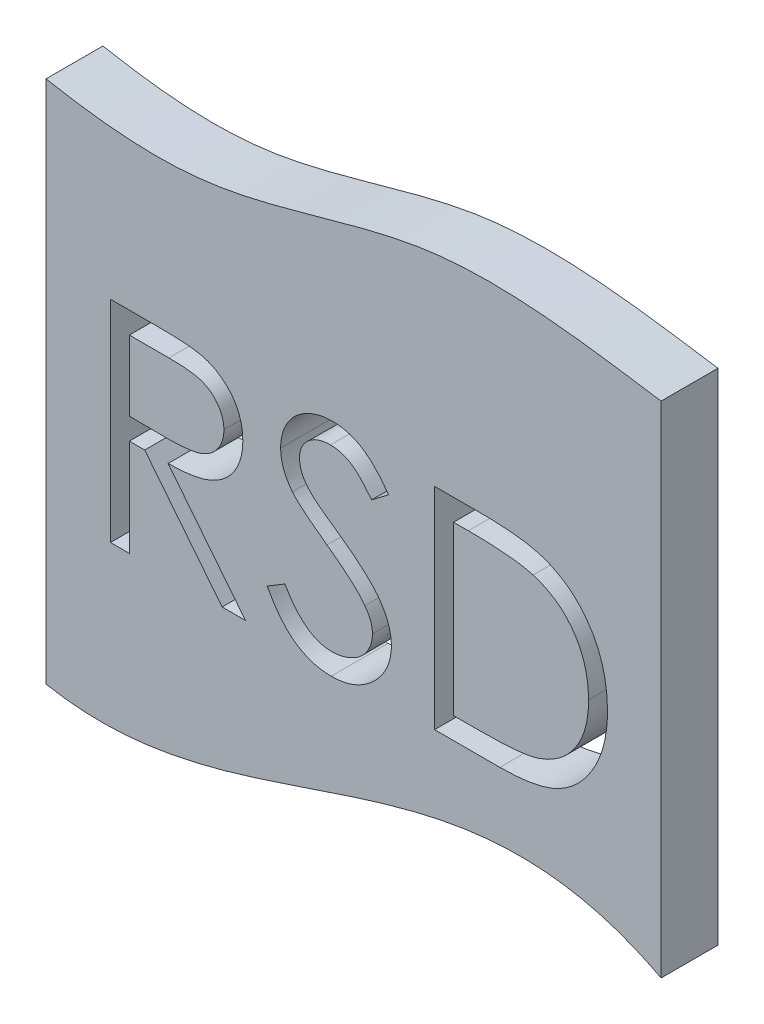
from build123d import *

# Parameters (mm, degrees)
BOSS_EXTRUDE2_DEPTH = 50
CUT_EXTRUDE3_DEPTH  = 50


with BuildPart() as part:
    # Sketch4 → Boss-Extrude2 (new body)
    with BuildSketch(Plane.XY):
        with BuildLine():
            Line((-253.859566444, 177.777181876), (-253.859566444, -283.005856695))
            add(Edge.make_bspline(
                [(-253.859566444, -283.005856695), (-207.170598057, -291.878132089), (-28.434679126, -271.164662134), (144.41760812, -161.038723154), (286.771817679, -236.372653984)],
                knots=[0.159405612, 0.159405612, 0.159405612, 0.159405612, 0.373982024, 1, 1, 1, 1], degree=3))
            Line((286.771817679, -236.372653984), (286.771817679, 202.798469011))
            add(Edge.make_bspline(
                [(-253.859566444, 177.777181876), (-207.700562223, 169.018800488), (-94.63538463, 157.865945475), (81.209450827, 234.424705463), (218.105040902, 213.363008386), (286.771817679, 202.798469011)],
                knots=[0.162783467, 0.162783467, 0.162783467, 0.162783467, 0.375755947, 0.686879417, 1, 1, 1, 1], degree=3))
        make_face()
    extrude(amount=BOSS_EXTRUDE2_DEPTH)

    # Sketch5 → Cut-Extrude3 (cut)
    with BuildSketch(Plane.XY.offset(50)):
        with BuildLine():
            Line((-197.245797461, 38.343525558), (-160.181870177, 38.343525558))
            add(Edge.make_bspline(
                [(-160.181870177, 38.343525558), (-155.4336297, 38.316492782), (-148.627104323, 38.331563473), (-139.973554774, 37.978720031), (-134.416174474, 37.76159426), (-129.484068309, 37.36377549), (-124.131071162, 36.899953135), (-120.448225941, 36.31907212), (-118.220607156, 35.820655633)],
                knots=[0, 0, 0, 0, 0.338434414, 0.484822051, 0.617157578, 0.734698361, 0.837385184, 1, 1, 1, 1], degree=3))
            add(Edge.make_bspline(
                [(-118.220607156, 35.820655633), (-115.522888444, 35.227944972), (-111.600210412, 33.991945188), (-106.64597839, 31.801900044), (-103.164274698, 29.900187843), (-99.897508952, 27.699825482), (-96.811475012, 25.240984948), (-93.892309247, 22.536535556), (-91.25802815, 19.518449015), (-88.774175902, 16.352098606), (-86.679257402, 12.928191369), (-84.873472947, 9.347771042), (-83.43541583, 5.574411492), (-82.278794332, 1.644759507), (-81.167985575, -3.935337325), (-80.889371197, -8.258757512), (-80.896972674, -11.186347238)],
                knots=[0, 0, 0, 0, 0.127063766, 0.188744538, 0.249132103, 0.309452533, 0.369826676, 0.430650142, 0.492351932, 0.554072106, 0.615689784, 0.676797703, 0.738439048, 0.80131691, 0.865184512, 1, 1, 1, 1], degree=3))
            add(Edge.make_bspline(
                [(-80.896972674, -11.186347238), (-80.880089433, -15.992319417), (-81.698527638, -23.126866777), (-84.859650144, -31.976518581), (-88.048528797, -38.01744681), (-92.114416305, -43.463182357), (-96.999706707, -48.246331358), (-102.708505903, -52.248946618), (-108.022874338, -55.024574308), (-112.717336352, -56.802196988), (-116.58201545, -58.052961732), (-120.797725883, -59.019293307), (-125.324078983, -59.885143673), (-130.179895437, -60.538235261), (-137.287689434, -61.198806908), (-142.791377097, -61.370129199), (-146.565792787, -61.384038545)],
                knots=[0, 0, 0, 0, 0.153720644, 0.22671353, 0.299191166, 0.371189997, 0.443006414, 0.516689173, 0.593217217, 0.633872918, 0.676989142, 0.722899506, 0.771958611, 0.824211323, 0.879378651, 1, 1, 1, 1], degree=3))
            Line((-146.565792787, -61.384038545), (-78.522506862, -146.864807775))
            Line((-78.522506862, -146.864807775), (-99.076476547, -146.864807775))
            Line((-99.076476547, -146.864807775), (-167.119762471, -61.384038545))
            Line((-167.119762471, -61.384038545), (-180.624536777, -61.384038545))
            Line((-180.624536777, -61.384038545), (-180.624536777, -146.864807775))
            Line((-180.624536777, -146.864807775), (-197.245797461, -146.864807775))
            Line((-197.245797461, -146.864807775), (-197.245797461, 38.343525558))
        make_face()
        with BuildLine():
            Line((-180.624536777, 19.347799062), (-180.624536777, -42.388312049))
            Line((-180.624536777, -42.388312049), (-146.7141969, -42.648019247))
            add(Edge.make_bspline(
                [(-146.7141969, -42.648019247), (-143.644599597, -42.697311401), (-139.2027504, -42.534467377), (-133.488513008, -42.197702403), (-129.676344177, -41.830733338), (-126.184187112, -41.356626827), (-123.013768157, -40.763844531), (-120.159917334, -40.073163056), (-116.831534127, -39.004163072), (-113.114865707, -37.310510084), (-109.075601714, -34.846419418), (-105.636101452, -31.747136976), (-102.729264597, -28.203124184), (-100.396920834, -24.306542188), (-98.178575391, -18.679287666), (-97.506840319, -14.174786166), (-97.518233358, -11.14924621)],
                knots=[0, 0, 0, 0, 0.138913286, 0.20118457, 0.259124428, 0.312255041, 0.36068151, 0.405086143, 0.445101659, 0.51877778, 0.589461579, 0.658462242, 0.727283218, 0.796322487, 0.863174893, 1, 1, 1, 1], degree=3))
            add(Edge.make_bspline(
                [(-97.518233358, -11.14924621), (-97.528006954, -8.205288588), (-98.140544416, -3.76200421), (-100.479411083, 1.690880257), (-102.822313414, 5.509423376), (-105.68044231, 8.975812206), (-109.030833127, 11.941629299), (-112.782947281, 14.388999768), (-116.289786294, 15.952918691), (-119.424265125, 16.911760148), (-122.145750927, 17.586512508), (-125.220816523, 18.12860101), (-128.664393856, 18.563007973), (-132.461775715, 18.936054969), (-138.249691605, 19.286660183), (-142.768402967, 19.358323321), (-145.897974277, 19.347799062)],
                knots=[0, 0, 0, 0, 0.136364825, 0.204019354, 0.273063739, 0.34291332, 0.410965444, 0.479168767, 0.549308007, 0.587651576, 0.630646669, 0.678878786, 0.731934299, 0.791111423, 0.85528319, 1, 1, 1, 1], degree=3))
            Line((-145.897974277, 19.347799062), (-180.624536777, 19.347799062))
        make_face(mode=Mode.SUBTRACT)
        with BuildLine():
            Line((-59.526780367, -111.136517511), (-43.870146419, -101.749957348))
            add(Edge.make_bspline(
                [(-43.870146419, -101.749957348), (-41.15894546, -106.456604833), (-36.8772392, -113.057045278), (-30.146479571, -120.53154576), (-25.121180156, -124.919030584), (-19.920952012, -128.367026978), (-12.777482046, -131.618288966), (-7.017325499, -132.6280394), (-3.207419389, -132.618012903)],
                knots=[0, 0, 0, 0, 0.3046461, 0.438546905, 0.562322299, 0.677432543, 0.786897393, 1, 1, 1, 1], degree=3))
            add(Edge.make_bspline(
                [(-3.207419389, -132.618012903), (0.013579203, -132.647062287), (4.812980182, -132.081140873), (10.977799759, -130.296090153), (15.349212047, -128.403029714), (19.428835368, -126.109059344), (23.006394867, -123.339232203), (26.099039367, -120.237962105), (28.629405444, -116.778081742), (30.568696785, -113.057343717), (32.561815547, -107.974358255), (33.028454039, -103.89911073), (33.0773863, -101.230542952)],
                knots=[0, 0, 0, 0, 0.180930311, 0.27008822, 0.360156133, 0.448342532, 0.532665842, 0.613833704, 0.693981527, 0.772715977, 0.849335172, 1, 1, 1, 1], degree=3))
            add(Edge.make_bspline(
                [(33.0773863, -101.230542952), (33.094815335, -98.09243764), (31.830914969, -91.545159102), (28.455217203, -85.811421857), (26.436302232, -83.051039079)],
                knots=[0, 0, 0, 0, 0.477158319, 1, 1, 1, 1], degree=3))
            add(Edge.make_bspline(
                [(26.436302232, -83.051039079), (24.729300621, -80.799420776), (21.841534594, -77.38499802), (17.360695409, -73.029388839), (13.450980801, -69.374269948), (8.998654149, -65.655110697), (2.285724013, -60.17583676), (-3.183202563, -56.236262293), (-6.954623249, -53.518620542)],
                knots=[0, 0, 0, 0, 0.189529918, 0.299197872, 0.418925887, 0.548376285, 0.68813637, 1, 1, 1, 1], degree=3))
            add(Edge.make_bspline(
                [(-6.954623249, -53.518620542), (-10.702399478, -50.895864446), (-15.947794012, -47.004071212), (-22.497588256, -41.9377142), (-26.585476519, -38.641504919), (-30.097989777, -35.646920127), (-33.748897097, -32.379295518), (-36.025122273, -29.906314531), (-37.303264408, -28.327022319)],
                knots=[0, 0, 0, 0, 0.347081672, 0.495567816, 0.628357302, 0.74551967, 0.845830751, 1, 1, 1, 1], degree=3))
            add(Edge.make_bspline(
                [(-37.303264408, -28.327022319), (-38.940912922, -26.206807924), (-41.223943107, -22.951866322), (-43.663691978, -18.31144596), (-45.080773269, -14.793164869), (-46.271803996, -11.235193644), (-47.349975838, -6.369244497), (-47.668580058, -2.628805622), (-47.654451307, -0.130240801)],
                knots=[0, 0, 0, 0, 0.262558979, 0.388264447, 0.512667355, 0.63372227, 0.75539386, 1, 1, 1, 1], degree=3))
            add(Edge.make_bspline(
                [(-47.654451307, -0.130240801), (-47.663937589, 3.745313188), (-46.932752896, 9.510668151), (-44.466467218, 16.777456744), (-41.913833743, 21.874908011), (-38.618584255, 26.529773337), (-34.806361128, 30.795603951), (-30.265459801, 34.381555813), (-25.283176947, 37.515387664), (-19.829986257, 39.965848865), (-12.153347609, 42.460847346), (-6.063352515, 43.040165002), (-2.020186483, 43.092457182)],
                knots=[0, 0, 0, 0, 0.165779888, 0.246280008, 0.327460928, 0.408796954, 0.489715241, 0.571376032, 0.655523321, 0.741019483, 0.826546761, 1, 1, 1, 1], degree=3))
            add(Edge.make_bspline(
                [(-2.020186483, 43.092457182), (2.314622359, 43.099439994), (8.823832067, 42.302299885), (17.033896376, 39.409430124), (21.978497072, 36.968322103), (25.848451644, 34.526771112), (28.799763521, 32.303322774), (31.790445828, 29.743420898), (34.844831678, 26.84056037), (37.91028651, 23.567424554), (42.20356879, 18.597363447), (45.307483475, 14.582992435), (47.324181172, 11.742088258)],
                knots=[0, 0, 0, 0, 0.213251813, 0.318830447, 0.426793531, 0.483645951, 0.543603822, 0.60830765, 0.67712676, 0.750685636, 0.828713418, 1, 1, 1, 1], degree=3))
            Line((47.324181172, 11.742088258), (32.298264705, 0.352072567))
            add(Edge.make_bspline(
                [(32.298264705, 0.352072567), (30.576466815, 2.623569698), (27.963399862, 5.808236696), (24.490451414, 9.803476345), (22.027557829, 12.30491276), (19.731218493, 14.564486112), (17.502546108, 16.499143814), (15.373475969, 18.127618191), (12.689696194, 19.865855803), (9.318045249, 21.586788814), (3.639786971, 23.552499648), (-0.866881177, 24.07851553), (-3.875237899, 24.096730686)],
                knots=[0, 0, 0, 0, 0.189629101, 0.274184089, 0.352183161, 0.423198873, 0.488550946, 0.548473346, 0.601440164, 0.701198082, 0.799591802, 1, 1, 1, 1], degree=3))
            add(Edge.make_bspline(
                [(-3.875237899, 24.096730686), (-7.55670101, 24.149540636), (-12.965394218, 23.362199599), (-19.430778631, 20.429724305), (-23.482616362, 17.452837374), (-26.851574569, 13.921626346), (-30.134820682, 8.483074243), (-31.027727319, 3.766718701), (-31.033190623, 0.648880793)],
                knots=[0, 0, 0, 0, 0.275902964, 0.402370856, 0.528413645, 0.650356379, 0.765895086, 1, 1, 1, 1], degree=3))
            add(Edge.make_bspline(
                [(-31.033190623, 0.648880793), (-31.096635464, -1.344781388), (-30.644258932, -4.303743247), (-29.642078623, -8.190588936), (-28.462185308, -11.097157245), (-26.829033936, -14.0333487), (-23.799502403, -18.30269438), (-20.910920487, -21.27294125), (-18.826952309, -23.281282468)],
                knots=[0, 0, 0, 0, 0.214745861, 0.32293856, 0.434116163, 0.553412311, 0.686072985, 1, 1, 1, 1], degree=3))
            add(Edge.make_bspline(
                [(-18.826952309, -23.281282468), (-17.87508645, -24.153606504), (-16.134407066, -25.586517149), (-13.371752941, -27.645082857), (-10.543344044, -29.793550256), (-7.158081199, -32.284548124), (-1.548263537, -36.276303029), (2.898650469, -39.491511959), (6.067837689, -41.720493539)],
                knots=[0, 0, 0, 0, 0.124951974, 0.218093899, 0.333502411, 0.468789179, 0.624937586, 1, 1, 1, 1], degree=3))
            add(Edge.make_bspline(
                [(6.067837689, -41.720493539), (9.9650981, -44.543815601), (15.594242806, -48.68338093), (22.529709949, -54.432700698), (27.052224005, -58.474203626), (31.120257169, -62.365100456), (34.688898341, -66.151975393), (37.794158959, -69.807761367), (41.138202563, -74.494701395), (44.548951324, -80.251201096), (48.41297898, -89.474235175), (49.694967663, -96.724299035), (49.698646984, -101.49025015)],
                knots=[0, 0, 0, 0, 0.187773439, 0.272396139, 0.351320997, 0.424334774, 0.491908784, 0.55423322, 0.611267658, 0.716347845, 0.814540086, 1, 1, 1, 1], degree=3))
            add(Edge.make_bspline(
                [(49.698646984, -101.49025015), (49.750027063, -104.782422813), (49.212560528, -109.655509933), (47.641488327, -115.958229278), (45.895702737, -120.451514003), (43.761274419, -124.830071519), (41.053908928, -128.979161767), (37.915493433, -132.99058156), (34.315387541, -136.757377587), (30.375954937, -140.215270905), (26.212276196, -143.291301296), (21.817535617, -145.855958835), (17.21555594, -147.949317279), (12.40535318, -149.584479606), (5.62733603, -151.195746714), (0.346245867, -151.627451333), (-3.207419389, -151.613739399)],
                knots=[0, 0, 0, 0, 0.121774528, 0.18091956, 0.240256115, 0.300114444, 0.361145948, 0.423500582, 0.488669361, 0.553954105, 0.617581261, 0.680238427, 0.742187389, 0.804663212, 0.868258989, 1, 1, 1, 1], degree=3))
            add(Edge.make_bspline(
                [(-3.207419389, -151.613739399), (-5.989889838, -151.630387461), (-10.118126115, -151.294164644), (-15.527555521, -150.384135761), (-19.42302505, -149.318004043), (-23.234992226, -148.022388676), (-26.946953471, -146.427669945), (-30.560687335, -144.516440426), (-34.09645193, -142.331253248), (-37.545249666, -139.78819431), (-40.874747229, -136.826268763), (-44.194130285, -133.527133355), (-47.40565137, -129.801317332), (-50.573349939, -125.708537144), (-54.774441629, -119.546093635), (-57.665576487, -114.586688248), (-59.526780367, -111.136517511)],
                knots=[0, 0, 0, 0, 0.11369606, 0.169177916, 0.224159217, 0.278719878, 0.333794217, 0.389241459, 0.445822073, 0.503704281, 0.564293892, 0.627975416, 0.69503826, 0.765372726, 0.839611443, 1, 1, 1, 1], degree=3))
        make_face()
        with BuildLine():
            Line((87.690099975, -146.864807775), (87.690099975, 38.343525558))
            Line((87.690099975, 38.343525558), (125.087936514, 38.343525558))
            add(Edge.make_bspline(
                [(125.087936514, 38.343525558), (131.371418524, 38.317729169), (140.458646708, 38.185789085), (152.108357672, 37.480073788), (159.804398829, 36.741852334), (166.814114805, 35.831844121), (174.820698057, 34.397012421), (180.415684916, 32.88326952), (183.85596536, 31.665340462)],
                knots=[0, 0, 0, 0, 0.317405911, 0.458843612, 0.589366542, 0.707831319, 0.815770031, 1, 1, 1, 1], degree=3))
            add(Edge.make_bspline(
                [(183.85596536, 31.665340462), (188.126962143, 30.149798393), (194.311687503, 27.388040969), (201.947554397, 22.736120304), (207.304412698, 18.877521526), (212.214941634, 14.497378092), (216.872075238, 9.784916844), (221.085007036, 4.567911441), (224.943077121, -1.045212604), (228.421578902, -6.988395023), (231.445227516, -13.250293525), (233.956203491, -19.799113451), (236.041262998, -26.616636977), (237.682200364, -33.717873567), (239.208512107, -43.718045168), (239.683516082, -51.402331488), (239.655911941, -56.598005892)],
                knots=[0, 0, 0, 0, 0.121694296, 0.181154855, 0.239875389, 0.298701942, 0.357647424, 0.417604843, 0.478494041, 0.540407051, 0.602344994, 0.665004328, 0.728559309, 0.793650542, 0.860534268, 1, 1, 1, 1], degree=3))
            add(Edge.make_bspline(
                [(239.655911941, -56.598005892), (239.674363784, -61.110765124), (239.276464934, -67.776787551), (238.11083794, -76.498167272), (236.787195442, -82.721499064), (235.17797595, -88.771359409), (233.116233312, -94.583317737), (230.754242601, -100.210677104), (227.999944196, -105.577352015), (224.976210565, -110.661763763), (221.731268836, -115.454718803), (218.268576905, -119.887824286), (214.555116364, -123.974505013), (210.638874693, -127.708600181), (206.494212203, -131.121302741), (202.110434098, -134.145836799), (197.507175023, -136.901055745), (192.550146505, -139.304545132), (187.145456977, -141.338151038), (181.270056903, -143.023294853), (174.938369324, -144.42963534), (168.139447971, -145.543758655), (158.146463295, -146.577703972), (150.397363104, -146.892632727), (145.085390774, -146.864807775)],
                knots=[0, 0, 0, 0, 0.0908068, 0.134295271, 0.177024386, 0.218822734, 0.260244116, 0.301079867, 0.341613894, 0.381583419, 0.420119591, 0.458074619, 0.494738488, 0.531194623, 0.566933698, 0.602712651, 0.638326606, 0.674853249, 0.713467371, 0.754441804, 0.797815361, 0.843989456, 0.89307157, 1, 1, 1, 1], degree=3))
            Line((145.085390774, -146.864807775), (87.690099975, -146.864807775))
        make_face()
        with BuildLine():
            Line((104.311360659, -127.86908128), (125.570249882, -127.86908128))
            add(Edge.make_bspline(
                [(125.570249882, -127.86908128), (131.445338244, -127.866207122), (139.897497992, -127.754136593), (150.668503871, -127.246634444), (157.660137478, -126.74100779), (163.918932, -126.06825341), (170.847832228, -125.142845964), (175.625863514, -124.067137167), (178.513417283, -123.157250684)],
                knots=[0, 0, 0, 0, 0.330627932, 0.475548836, 0.60674619, 0.725023803, 0.829742387, 1, 1, 1, 1], degree=3))
            add(Edge.make_bspline(
                [(178.513417283, -123.157250684), (181.86210087, -122.021565563), (186.79398065, -120.12722677), (192.838900209, -116.696250775), (197.078210026, -113.871182863), (201.011287627, -110.661784241), (204.684991668, -107.139127191), (208.091858575, -103.284938071), (211.196709785, -99.104093793), (213.975267963, -94.622591021), (216.381476552, -89.884494397), (218.490200745, -84.941718508), (220.145690293, -79.718354125), (221.441690291, -74.261126585), (222.694918865, -66.540465233), (223.036221286, -60.589637648), (223.034651257, -56.560904864)],
                knots=[0, 0, 0, 0, 0.123338231, 0.183124538, 0.241782995, 0.300578883, 0.359680075, 0.418881641, 0.479530664, 0.540850536, 0.602303396, 0.664463212, 0.727805723, 0.792894815, 0.859672328, 1, 1, 1, 1], degree=3))
            add(Edge.make_bspline(
                [(223.034651257, -56.560904864), (223.08360159, -52.304360169), (222.641000801, -46.033930627), (221.30182217, -37.890918216), (219.886444107, -32.124131015), (218.079850083, -26.584378757), (215.826014855, -21.302261232), (213.250704803, -16.222004458), (210.186662829, -11.460859217), (206.830917263, -6.958021461), (203.106759899, -2.832885534), (199.073325927, 0.923816424), (194.774714271, 4.371069753), (190.089377434, 7.368395455), (183.39055144, 10.996558941), (177.953823534, 13.000864901), (174.246799027, 14.153655099)],
                knots=[0, 0, 0, 0, 0.137812606, 0.203226247, 0.267174055, 0.330024003, 0.391794272, 0.453084399, 0.514333908, 0.574999993, 0.634865483, 0.694116315, 0.753441622, 0.8131258, 0.874079686, 1, 1, 1, 1], degree=3))
            add(Edge.make_bspline(
                [(174.246799027, 14.153655099), (170.965028811, 15.146210271), (165.598535639, 16.270035505), (157.936611428, 17.369214221), (151.16925502, 18.115827822), (143.705765754, 18.648223194), (132.354484696, 19.209155172), (123.481626314, 19.368287098), (117.333821596, 19.347799062)],
                knots=[0, 0, 0, 0, 0.179284514, 0.286582528, 0.405111483, 0.535592873, 0.67819021, 1, 1, 1, 1], degree=3))
            Line((117.333821596, 19.347799062), (104.311360659, 19.347799062))
            Line((104.311360659, 19.347799062), (104.311360659, -127.86908128))
        make_face(mode=Mode.SUBTRACT)
    extrude(amount=-CUT_EXTRUDE3_DEPTH, mode=Mode.SUBTRACT)


solid = part.part
